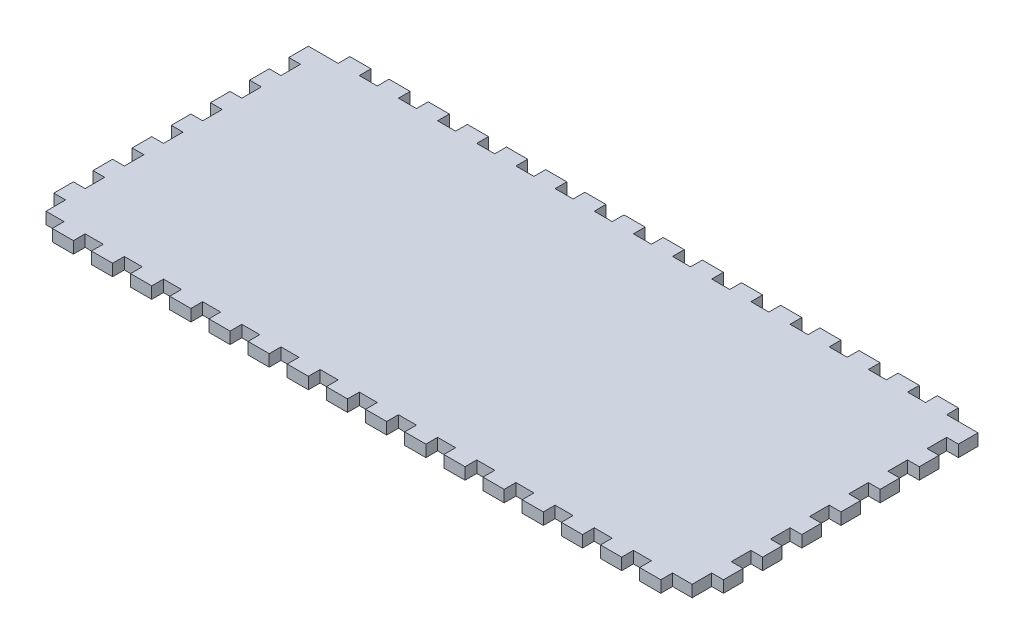
from build123d import *

# Parameters (mm, degrees)
EXTRUDE_1_DEPTH = 3


with BuildPart() as part:
    # Эскиз1 → Бобышка-Вытянуть1 (new body)
    with BuildSketch(Plane(origin=(0, 0, 0), x_dir=(1, 0, 0), z_dir=(0, 1, 0))):
        Polygon((4.6, 70), (4.6, 73), (10, 73), (10, 70), (14.6, 70), (14.6, 73), (20, 73), (20, 70), (24.6, 70), (24.6, 73), (30, 73), (30, 70), (34.6, 70), (34.6, 73), (40, 73), (40, 70), (44.6, 70), (44.6, 73), (50, 73), (50, 70), (54.6, 70), (54.6, 73), (60, 73), (60, 70), (64.6, 70), (64.6, 73), (70, 73), (70, 70), (74.6, 70), (74.6, 73), (80, 73), (80, 70), (84.6, 70), (84.6, 73), (90, 73), (90, 70), (94.6, 70), (94.6, 73), (100, 73), (100, 70), (104.6, 70), (104.6, 73), (110, 73), (110, 70), (114.6, 70), (114.6, 73), (120, 73), (120, 70), (124.6, 70), (124.6, 73), (130, 73), (130, 70), (134.6, 70), (134.6, 73), (140, 73), (140, 70), (144.6, 70), (144.6, 73), (150, 73), (150, 70), (154.6, 70), (154.6, 73), (160, 73), (160, 70), (168, 70), (168, 65), (165, 65), (165, 60), (168, 60), (168, 55), (165, 55), (165, 50), (168, 50), (168, 45), (165, 45), (165, 40), (168, 40), (168, 35), (165, 35), (165, 30), (168, 30), (168, 25), (165, 25), (165, 20), (168, 20), (168, 15), (165, 15), (165, 10), (168, 10), (168, 5), (165, 5), (165, 0), (160, 0), (160, -3), (154.6, -3), (154.6, 0), (150, 0), (150, -3), (144.6, -3), (144.6, 0), (140, 0), (140, -3), (134.6, -3), (134.6, 0), (130, 0), (130, -3), (124.6, -3), (124.6, 0), (120, 0), (120, -3), (114.6, -3), (114.6, 0), (110, 0), (110, -3), (104.6, -3), (104.6, 0), (100, 0), (100, -3), (94.6, -3), (94.6, 0), (90, 0), (90, -3), (84.6, -3), (84.6, 0), (80, 0), (80, -3), (74.6, -3), (74.6, 0), (70, 0), (70, -3), (64.6, -3), (64.6, 0), (60, 0), (60, -3), (54.6, -3), (54.6, 0), (50, 0), (50, -3), (44.6, -3), (44.6, 0), (40, 0), (40, -3), (34.6, -3), (34.6, 0), (30, 0), (30, -3), (24.6, -3), (24.6, 0), (20, 0), (20, -3), (14.6, -3), (14.6, 0), (10, 0), (10, -3), (4.6, -3), (4.6, 0), (0, 0), (0, 5), (-3, 5), (-3, 10), (0, 10), (0, 15), (-3, 15), (-3, 20), (0, 20), (0, 25), (-3, 25), (-3, 30), (0, 30), (0, 35), (-3, 35), (-3, 40), (0, 40), (0, 45), (-3, 45), (-3, 50), (0, 50), (0, 55), (-3, 55), (-3, 60), (0, 60), (0, 65), (-3, 65), (-3, 70), (0, 70), align=None)
    extrude(amount=EXTRUDE_1_DEPTH)


solid = part.part
